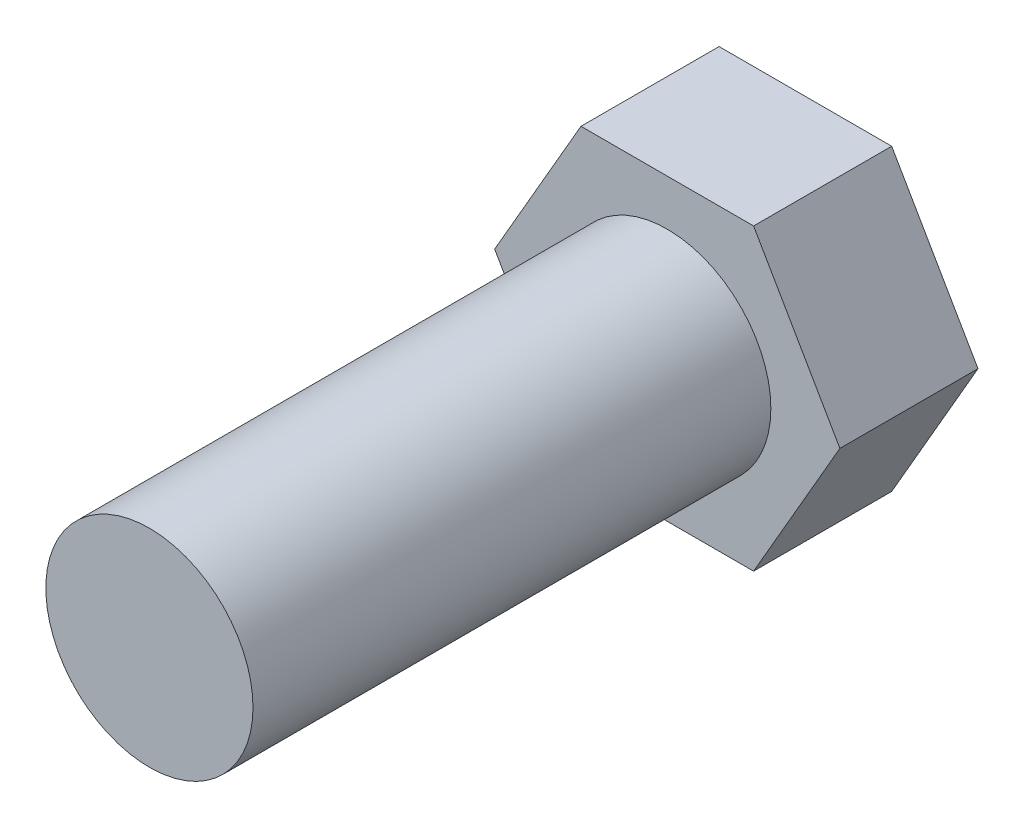
from build123d import *

# Parameters (mm, degrees)
CROQUIS2_R              = 3
SALIENTE_EXTRUIR1_DEPTH = 15
SALIENTE_EXTRUIR3_DEPTH = 4


with BuildPart() as part:
    # Croquis2 → Saliente-Extruir1 (new body)
    with BuildSketch(Plane.XY):
        Circle(CROQUIS2_R)
    extrude(amount=SALIENTE_EXTRUIR1_DEPTH)

    # Croquis3 → Saliente-Extruir3 (add)
    with BuildSketch(Plane(origin=(0, 0, 0), x_dir=(-1, 0, 0), z_dir=(0, 0, -1))):
        Polygon((5, 0), (2.5, 4.330127019), (-2.5, 4.330127019), (-5, 0), (-2.5, -4.330127019), (2.5, -4.330127019), align=None)
    extrude(amount=SALIENTE_EXTRUIR3_DEPTH)


solid = part.part
